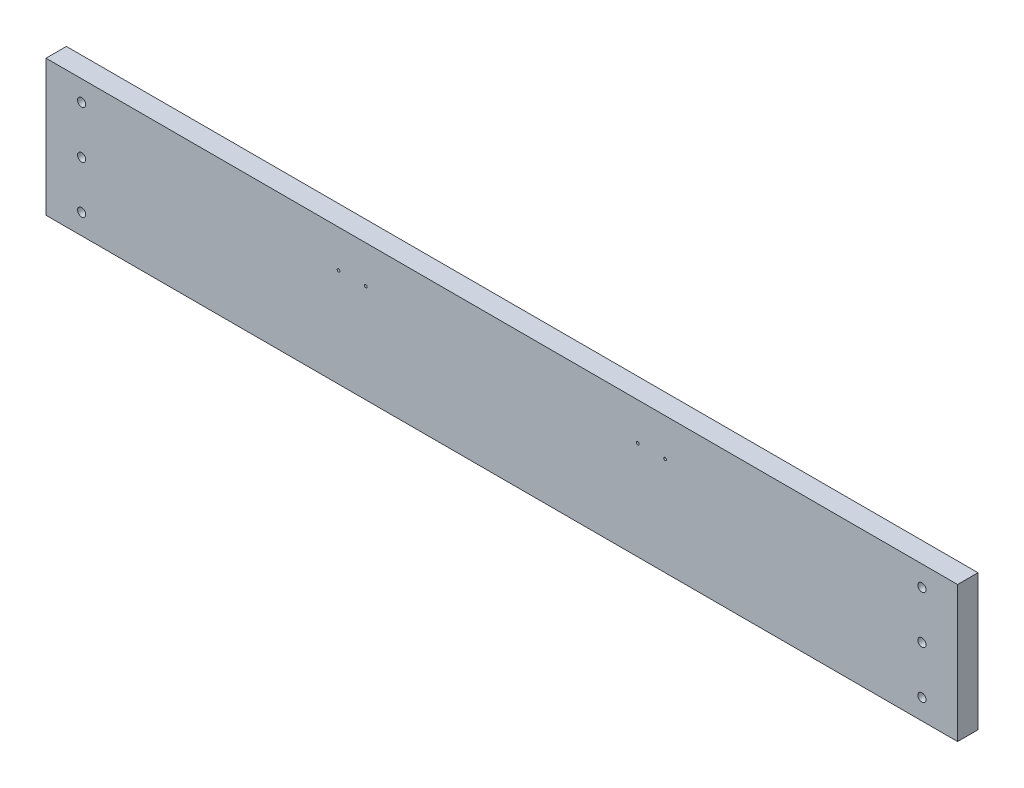
from build123d import *

# Parameters (mm, degrees)
SKETCH1_W           = 812.8
SKETCH1_H           = 19.05
SKETCH1_W_2         = 19.05
BOSS_EXTRUDE2_DEPTH = 127
SKETCH2_R           = 3.81
CUT_EXTRUDE1_DEPTH  = 19.05
SKETCH3_R           = 19.05
CUT_EXTRUDE2_DEPTH  = 5.08
SKETCH4_R           = 1.27
CUT_EXTRUDE3_DEPTH  = 19.05


with BuildPart() as part:
    # Sketch1 → Boss-Extrude2 (new body)
    with BuildSketch(Plane(origin=(0, 0, 0), x_dir=(1, 0, 0), z_dir=(0, 1, 0))):
        with Locations((406.4, -9.525)):
            Rectangle(SKETCH1_W, SKETCH1_H)
        with Locations((822.325, -9.525)):
            Rectangle(SKETCH1_W_2, SKETCH1_H)
        with Locations((-9.525, -9.525)):
            Rectangle(SKETCH1_W_2, SKETCH1_H)
    extrude(amount=BOSS_EXTRUDE2_DEPTH)

    # Sketch2 → Cut-Extrude1 (cut)
    with BuildSketch(Plane(origin=(0, 0, 0), x_dir=(-1, 0, 0), z_dir=(0, 0, -1))):
        with Locations((-14.224, 107.95)):
            Circle(SKETCH2_R)
        with Locations((-14.224, 63.5)):
            Circle(SKETCH2_R)
        with Locations((-14.224, 19.05)):
            Circle(SKETCH2_R)
        with Locations((-798.576, 19.05)):
            Circle(SKETCH2_R)
        with Locations((-798.576, 107.95)):
            Circle(SKETCH2_R)
        with Locations((-798.576, 63.5)):
            Circle(SKETCH2_R)
    extrude(amount=-CUT_EXTRUDE1_DEPTH, mode=Mode.SUBTRACT)

    # Sketch3 → Cut-Extrude2 (cut)
    with BuildSketch(Plane(origin=(0, 0, 0), x_dir=(-1, 0, 0), z_dir=(0, 0, -1))):
        with BuildLine():
            ThreePointArc((-663.448, 28.702), (-682.498, 9.652), (-701.548, 28.702))
            Line((-701.548, 28.702), (-701.548, 0))
            Line((-701.548, 0), (-663.448, 0))
            Line((-663.448, 0), (-663.448, 28.702))
        make_face()
        with Locations((-682.498, 28.702)):
            Circle(SKETCH3_R)
        with Locations((-406.4, 28.702)):
            Circle(SKETCH3_R)
        with BuildLine():
            Line((-425.45, 28.702), (-425.45, 0))
            Line((-425.45, 0), (-387.35, 0))
            Line((-387.35, 0), (-387.35, 28.702))
            ThreePointArc((-387.35, 28.702), (-406.4, 9.652), (-425.45, 28.702))
        make_face()
        with BuildLine():
            Line((-149.352, 28.702), (-149.352, 0))
            Line((-149.352, 0), (-111.252, 0))
            Line((-111.252, 0), (-111.252, 28.702))
            ThreePointArc((-111.252, 28.702), (-130.302, 9.652), (-149.352, 28.702))
        make_face()
        with Locations((-130.302, 28.702)):
            Circle(SKETCH3_R)
    extrude(amount=-CUT_EXTRUDE2_DEPTH, mode=Mode.SUBTRACT)

    # Sketch4 → Cut-Extrude3 (cut)
    with BuildSketch(Plane(origin=(0, 0, 0), x_dir=(-1, 0, 0), z_dir=(0, 0, -1))):
        with Locations((-558.8, 91.948)):
            Circle(SKETCH4_R)
        with Locations((-533.4, 91.948)):
            Circle(SKETCH4_R)
        with Locations((-279.4, 91.948)):
            Circle(SKETCH4_R)
        with Locations((-254, 91.948)):
            Circle(SKETCH4_R)
    extrude(amount=-CUT_EXTRUDE3_DEPTH, mode=Mode.SUBTRACT)


solid = part.part
